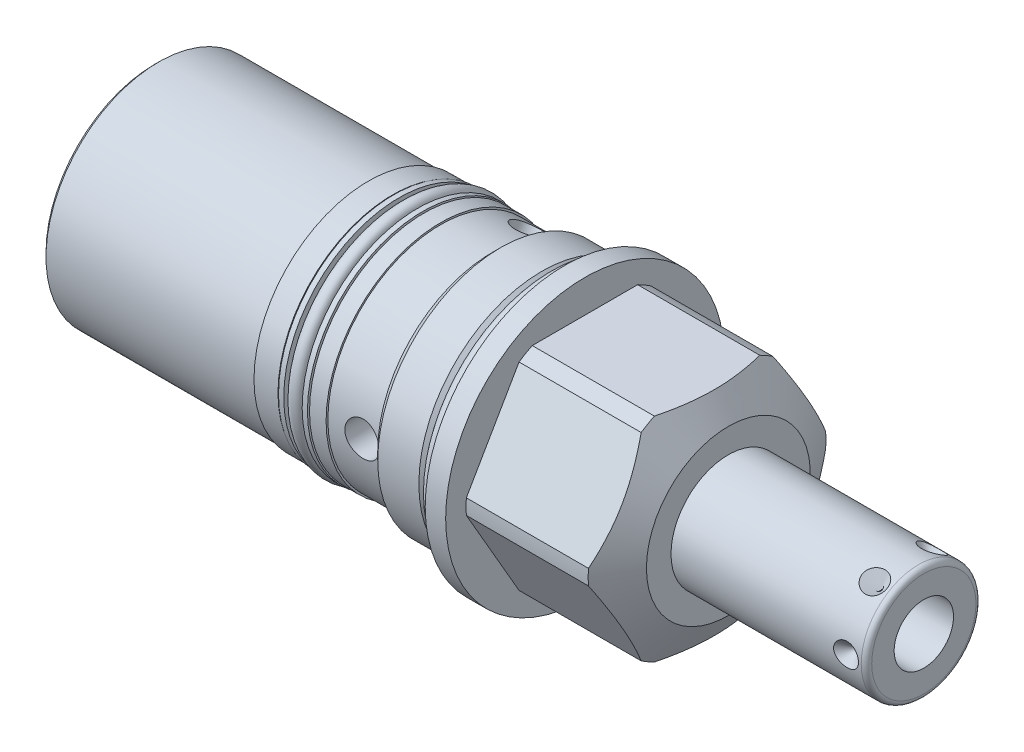
from build123d import *

# Parameters (mm, degrees)
SKETCH2_OUTSIDE_W  = 82.938
SKETCH2_OUTSIDE_H  = 82.938
CUT_EXTRUDE1_DEPTH = 27.7876
CIRPATTERN1_COUNT  = 6
SKETCH6_W          = 13.97
SKETCH6_H          = 0.3429
SKETCH7_R          = 3.1369
CUT_EXTRUDE2_DEPTH = 0.762
SKETCH8_W          = 6.1087
SKETCH8_H          = 2.032
SKETCH9_W          = 1.016
SKETCH9_H          = 2.1844
SKETCH10_W         = 3.3147
SKETCH10_H         = 12.7
CIRPATTERN2_COUNT  = 3
CHAMFER1_SIZE      = 0.762
SKETCH11_R         = 1.4732
SKETCH12_R         = 1.3081
SKETCH13_R         = 17.7927
EXTRUDE1_DEPTH     = 0.508
SKETCH14_R         = 3.1369
CUT_EXTRUDE4_DEPTH = 0.508


with BuildPart() as part:
    # Sketch1 → Revolve1 (revolve)
    with BuildSketch(Plane.XY, mode=Mode.PRIVATE) as revolve1_sk:
        Polygon((0, 26.9875), (3.9624, 26.9875), (3.9624, 23.0251), (27.62188784, 23.0251), (31.75, 15.875), (31.75, 0), (-79.375, 0), (-79.375, 21.844), (-13.9954, 21.844), (-13.9954, 22.1869), (-12.3698, 23.8125), (-4.4069, 23.8125), (-2.8956, 22.3012), (0, 22.3012), align=None)
    revolve(revolve1_sk.sketch.rotate(Axis((0, 0, 0), (1, 0, 0)), 90), axis=Axis((0, 0, 0), (1, 0, 0)))  # turned: the seam where the file's is

    # Sketch2 outside → Cut-Extrude1 (cut)
    with BuildSketch(Plane(origin=(31.75, 0, 0), x_dir=(0, 0, -1), z_dir=(1, 0, 0))):
        Rectangle(SKETCH2_OUTSIDE_W, SKETCH2_OUTSIDE_H)
        Polygon((11.91506618, 20.6375), (-11.91506618, 20.6375), (-23.830132361, 0), (-11.91506618, -20.6375), (11.91506618, -20.6375), (23.830132361, 0), align=None, mode=Mode.SUBTRACT)
    extrude(amount=-CUT_EXTRUDE1_DEPTH, mode=Mode.SUBTRACT)

    # Sketch3 → Revolve2 (revolve)
    with BuildSketch(Plane.XY, mode=Mode.PRIVATE) as revolve2_sk:
        with BuildLine():
            Line((31.75, 11.1125), (68.6054, 11.1125))
            ThreePointArc((68.6054, 11.1125), (69.32382049, 10.81492049), (69.6214, 10.0965))
            Line((69.6214, 10.0965), (69.6214, 0))
            Line((69.6214, 0), (31.75, 0))
            Line((31.75, 0), (31.75, 11.1125))
        make_face()
    revolve(revolve2_sk.sketch.rotate(Axis((0, 0, 0), (1, 0, 0)), 90), axis=Axis((0, 0, 0), (1, 0, 0)))  # turned: the seam where the file's is

    # Sketch4 → Cut-Revolve1 (revolve, cut)
    with BuildSketch(Plane(origin=(0, 0, 0), x_dir=(1, 0, 0), z_dir=(0, 1, 0)), mode=Mode.PRIVATE) as cut_revolve1_sk:
        Polygon((68.072, 11.1125), (65.659, 11.1125), (65.659, 8.6995), align=None)
    cut_revolve1 = revolve(cut_revolve1_sk.sketch.rotate(Axis((65.659, 0, -10.073804773), (0, 0, 1)), 180), axis=Axis((65.659, 0, -10.073804773), (0, 0, 1)), mode=Mode.SUBTRACT)  # turned: the seam where the file's is

    # CirPattern1: Cut-Revolve1 ×6 about axis
    cirpattern1_axis = Axis((0, 0, 0), (-1, 0, 0))
    for i in range(1, CIRPATTERN1_COUNT):
        add(cut_revolve1.rotate(cirpattern1_axis, i * 360 / CIRPATTERN1_COUNT), mode=Mode.SUBTRACT)

    # Sketch5 → Cut-Revolve2 (revolve, cut)
    with BuildSketch(Plane.XY, mode=Mode.PRIVATE) as cut_revolve2_sk:
        Polygon((69.6214, 5.7531), (52.6034, 5.7531), (49.146588773, 0), (69.6214, 0), align=None)
    revolve(cut_revolve2_sk.sketch.rotate(Axis((0, 0, 0), (1, 0, 0)), 90), axis=Axis((0, 0, 0), (1, 0, 0)), mode=Mode.SUBTRACT)  # turned: the seam where the file's is

    # Sketch6 → Revolve3 (revolve)
    with BuildSketch(Plane.XY, mode=Mode.PRIVATE) as revolve3_sk:
        with Locations((-30.988, 22.01545)):
            Rectangle(SKETCH6_W, SKETCH6_H)
    revolve(revolve3_sk.sketch.rotate(Axis((0, 0, 0), (-1, 0, 0)), 270), axis=Axis((0, 0, 0), (-1, 0, 0)))  # turned: the seam where the file's is

    # Sketch7 → Cut-Extrude2 (cut)
    with BuildSketch(Plane.ZY.offset(79.375)):
        Circle(SKETCH7_R)
    extrude(amount=-CUT_EXTRUDE2_DEPTH, mode=Mode.SUBTRACT)

    # Sketch8 → Cut-Revolve3 (revolve, cut)
    with BuildSketch(Plane.XY, mode=Mode.PRIVATE) as cut_revolve3_sk:
        with Locations((-30.27045, 21.1709)):
            Rectangle(SKETCH8_W, SKETCH8_H)
    revolve(cut_revolve3_sk.sketch.rotate(Axis((0, 0, 0), (-1, 0, 0)), 270), axis=Axis((0, 0, 0), (-1, 0, 0)), mode=Mode.SUBTRACT)  # turned: the seam where the file's is

    # Sketch9 → Revolve4 (revolve)
    with BuildSketch(Plane.XY, mode=Mode.PRIVATE) as revolve4_sk:
        with Locations((-27.9781, 21.2471)):
            Rectangle(SKETCH9_W, SKETCH9_H)
        with Locations((-32.5628, 21.2471)):
            Rectangle(SKETCH9_W, SKETCH9_H)
    revolve(revolve4_sk.sketch.rotate(Axis((0, 0, 0), (-1, 0, 0)), 270), axis=Axis((0, 0, 0), (-1, 0, 0)))  # turned: the seam where the file's is

    # Sketch10 → Cut-Revolve4 (revolve, cut)
    with BuildSketch(Plane(origin=(0, 0, 0), x_dir=(1, 0, 0), z_dir=(0, 1, 0))):
        with Locations((-19.05635, -17.4625)):
            Rectangle(SKETCH10_W, SKETCH10_H)
    cut_revolve4 = revolve(axis=Axis((-17.399, 0, -23.036850257), (0, 0, 1)), mode=Mode.SUBTRACT)

    # CirPattern2: Cut-Revolve4 ×3 about axis
    cirpattern2_axis = Axis((0, 0, 0), (1, 0, 0))
    for i in range(1, CIRPATTERN2_COUNT):
        add(cut_revolve4.rotate(cirpattern2_axis, i * 360 / CIRPATTERN2_COUNT), mode=Mode.SUBTRACT)

    # Chamfer1
    chamfer1_edges = [part.edges().sort_by_distance(p)[0] for p in [
        (-79.375, 0, -21.844),
    ]]
    chamfer(chamfer1_edges, length=CHAMFER1_SIZE)

    # Sketch13 → Extrude1 (add)
    with BuildSketch(Plane.ZY.offset(79.375)):
        with Locations(Location((0, 0, 0), (0, 0, 180))):  # turned: the seam where the file's is
            Circle(SKETCH13_R)
    extrude(amount=EXTRUDE1_DEPTH)

    # Sketch14 → Cut-Extrude4 (cut)
    with BuildSketch(Plane.ZY.offset(79.883)):
        Circle(SKETCH14_R)
    extrude(amount=-CUT_EXTRUDE4_DEPTH, mode=Mode.SUBTRACT)


with BuildPart() as body_2:
    # Sketch11 → Revolve5 (revolve)
    with BuildSketch(Plane.XY, mode=Mode.PRIVATE) as revolve5_sk:
        with Locations((-1.4732, 23.7744)):
            Circle(SKETCH11_R)
    revolve(revolve5_sk.sketch.rotate(Axis((0, 0, 0), (1, 0, 0)), 90), axis=Axis((0, 0, 0), (1, 0, 0)))  # turned: the seam where the file's is


with BuildPart() as body_3:
    # Sketch12 → Revolve7 (revolve)
    with BuildSketch(Plane.XY, mode=Mode.PRIVATE) as revolve7_sk:
        with Locations((-30.27045, 21.463)):
            Circle(SKETCH12_R)
    revolve(revolve7_sk.sketch.rotate(Axis((0, 0, 0), (-1, 0, 0)), 270), axis=Axis((0, 0, 0), (-1, 0, 0)))  # turned: the seam where the file's is


solid = Compound([part.part, body_2.part, body_3.part])
